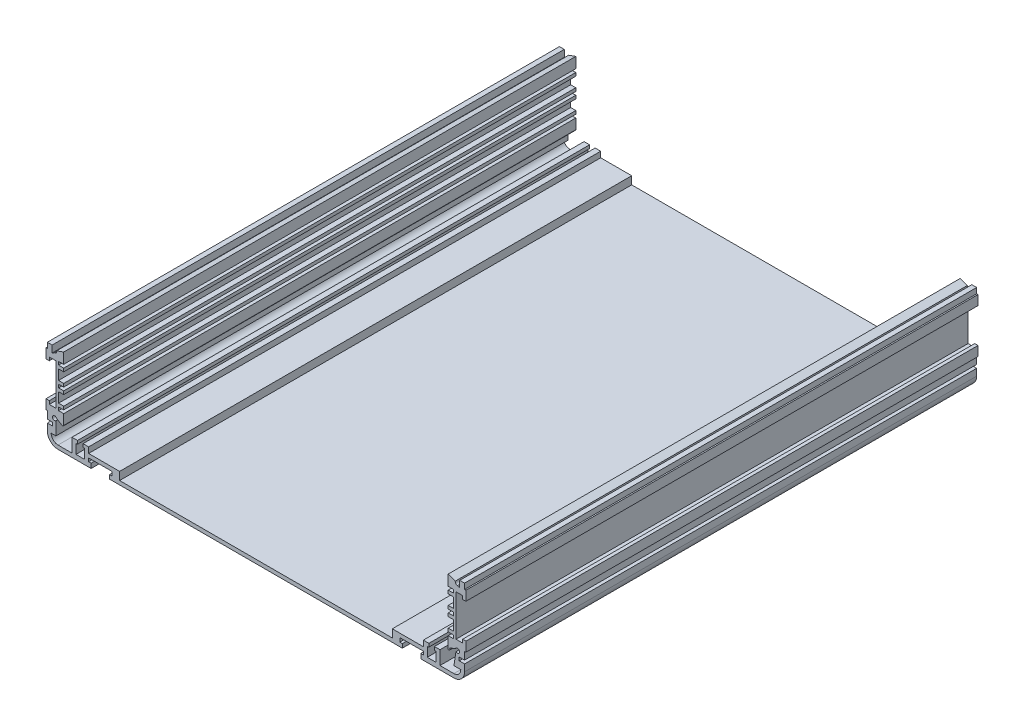
from build123d import *

# Parameters (mm, degrees)
MAINBODY_DEPTH = 304.8


with BuildPart() as part:
    # Sketch2 → MainBody (new body)
    with BuildSketch(Plane.XY):
        with BuildLine():
            Line((-87.11385, -52.07), (87.11385, -52.07))
            Line((87.11385, -52.07), (87.11385, -49.7078))
            Line((87.11385, -49.7078), (85.61385, -49.7078))
            Line((85.61385, -49.7078), (85.61385, -47.3456))
            Line((85.61385, -47.3456), (99.61385, -47.3456))
            Line((99.61385, -47.3456), (99.61385, -49.3141))
            Line((99.61385, -49.3141), (98.11385, -49.3141))
            Line((98.11385, -49.3141), (98.11385, -52.07))
            Line((98.11385, -52.07), (117.82425, -52.07))
            ThreePointArc((117.82425, -52.07), (122.314378061, -50.210128061), (124.17425, -45.72))
            Line((124.17425, -45.72), (124.17425, -41.656))
            Line((124.17425, -41.656), (120.99925, -41.656))
            Line((120.99925, -41.656), (120.99925, -39.6875))
            Line((120.99925, -39.6875), (124.17425, -39.6875))
            Line((124.17425, -39.6875), (124.17425, -35.2171))
            Line((124.17425, -35.2171), (124.968, -35.2171))
            Line((124.968, -35.2171), (124.968, -29.5021))
            Line((124.968, -29.5021), (122.9995, -29.5021))
            Line((122.9995, -29.5021), (122.9995, -31.4706))
            Line((122.9995, -31.4706), (119.0625, -31.4706))
            Line((119.0625, -31.4706), (119.0625, -7.0104))
            Line((119.0625, -7.0104), (122.9995, -7.0104))
            Line((122.9995, -7.0104), (122.9995, -8.9789))
            Line((122.9995, -8.9789), (124.968, -8.9789))
            Line((124.968, -8.9789), (124.968, -3.2639))
            Line((124.968, -3.2639), (124.17425, -3.2639))
            Line((124.17425, -3.2639), (124.17425, 0))
            Line((124.17425, 0), (121.29481323, 0))
            Line((121.29481323, 0), (121.29481323, -4.109997352))
            Line((121.29481323, -4.109997352), (120.011918892, -3.327689915))
            ThreePointArc((120.011918892, -3.327689915), (118.907723578, -2.871189246), (118.671208827, -1.699992881))
            Line((118.671208827, -1.699992881), (114.427, -0.1905))
            Line((114.427, -0.1905), (114.427, -6.5405))
            Line((114.427, -6.5405), (117.475, -6.5405))
            Line((117.475, -6.5405), (117.475, -8.4709))
            Line((117.475, -8.4709), (114.427, -8.4709))
            Line((114.427, -8.4709), (114.427, -10.4013))
            Line((114.427, -10.4013), (117.475, -10.4013))
            Line((117.475, -10.4013), (117.475, -16.3449))
            Line((117.475, -16.3449), (114.427, -16.3449))
            Line((114.427, -16.3449), (114.427, -18.2753))
            Line((114.427, -18.2753), (117.475, -18.2753))
            Line((117.475, -18.2753), (117.475, -20.2057))
            Line((117.475, -20.2057), (114.427, -20.2057))
            Line((114.427, -20.2057), (114.427, -22.1361))
            Line((114.427, -22.1361), (117.475, -22.1361))
            Line((117.475, -22.1361), (117.475, -28.0797))
            Line((117.475, -28.0797), (114.427, -28.0797))
            Line((114.427, -28.0797), (114.427, -30.0101))
            Line((114.427, -30.0101), (117.475, -30.0101))
            Line((117.475, -30.0101), (117.475, -31.9405))
            Line((117.475, -31.9405), (114.427, -31.9405))
            Line((114.427, -31.9405), (114.427, -39.0525))
            ThreePointArc((114.427, -39.0525), (115.382882445, -38.837450889), (115.167833333, -37.881568444))
            Line((115.167833333, -37.881568444), (118.737456339, -36.45102397))
            ThreePointArc((118.737456339, -36.45102397), (121.131104208, -36.728765521), (119.049383871, -37.942491573))
            Line((119.049383871, -37.942491573), (117.82425, -45.72))
            Line((117.82425, -45.72), (121.915072727, -45.72))
            ThreePointArc((121.915072727, -45.72), (120.716898491, -48.612648491), (117.82425, -49.810822727))
            Line((117.82425, -49.810822727), (109.51985, -49.810822727))
            Line((109.51985, -49.810822727), (109.51985, -41.656))
            Line((109.51985, -41.656), (106.21785, -41.656))
            Line((106.21785, -41.656), (106.21785, -43.6118))
            Line((106.21785, -43.6118), (107.15765, -43.6118))
            Line((107.15765, -43.6118), (107.15765, -49.3141))
            Line((107.15765, -49.3141), (101.97605, -49.3141))
            Line((101.97605, -49.3141), (101.97605, -43.6118))
            Line((101.97605, -43.6118), (102.91585, -43.6118))
            Line((102.91585, -43.6118), (102.91585, -41.656))
            Line((102.91585, -41.656), (99.61385, -41.656))
            Line((99.61385, -41.656), (99.61385, -45.0596))
            Line((99.61385, -45.0596), (81.154405407, -45.0596))
            Line((81.154405407, -45.0596), (81.154405407, -49.784))
            Line((81.154405407, -49.784), (-81.154405407, -49.784))
            Line((-81.154405407, -49.784), (-81.154405407, -45.0596))
            Line((-81.154405407, -45.0596), (-99.61385, -45.0596))
            Line((-99.61385, -45.0596), (-99.61385, -41.656))
            Line((-99.61385, -41.656), (-102.91585, -41.656))
            Line((-102.91585, -41.656), (-102.91585, -43.6118))
            Line((-102.91585, -43.6118), (-101.97605, -43.6118))
            Line((-101.97605, -43.6118), (-101.97605, -49.3141))
            Line((-101.97605, -49.3141), (-107.15765, -49.3141))
            Line((-107.15765, -49.3141), (-107.15765, -43.6118))
            Line((-107.15765, -43.6118), (-106.21785, -43.6118))
            Line((-106.21785, -43.6118), (-106.21785, -41.656))
            Line((-106.21785, -41.656), (-109.51985, -41.656))
            Line((-109.51985, -41.656), (-109.51985, -49.810822727))
            Line((-109.51985, -49.810822727), (-117.82425, -49.810822727))
            ThreePointArc((-117.82425, -49.810822727), (-120.716898491, -48.612648491), (-121.915072727, -45.72))
            Line((-121.915072727, -45.72), (-119.049383871, -45.72))
            Line((-119.049383871, -45.72), (-119.049383871, -37.942491573))
            ThreePointArc((-119.049383871, -37.942491573), (-121.131104208, -36.728765521), (-118.737456339, -36.45102397))
            Line((-118.737456339, -36.45102397), (-115.390113559, -38.471235131))
            ThreePointArc((-115.390113559, -38.471235131), (-114.749851886, -38.480556372), (-114.427, -37.927574858))
            Line((-114.427, -37.927574858), (-114.427, -31.9405))
            Line((-114.427, -31.9405), (-117.475, -31.9405))
            Line((-117.475, -31.9405), (-117.475, -30.0101))
            Line((-117.475, -30.0101), (-114.427, -30.0101))
            Line((-114.427, -30.0101), (-114.427, -28.0797))
            Line((-114.427, -28.0797), (-117.475, -28.0797))
            Line((-117.475, -28.0797), (-117.475, -22.1361))
            Line((-117.475, -22.1361), (-114.427, -22.1361))
            Line((-114.427, -22.1361), (-114.427, -20.2057))
            Line((-114.427, -20.2057), (-117.475, -20.2057))
            Line((-117.475, -20.2057), (-117.475, -18.2753))
            Line((-117.475, -18.2753), (-114.427, -18.2753))
            Line((-114.427, -18.2753), (-114.427, -16.3449))
            Line((-114.427, -16.3449), (-117.475, -16.3449))
            Line((-117.475, -16.3449), (-117.475, -10.4013))
            Line((-117.475, -10.4013), (-114.427, -10.4013))
            Line((-114.427, -10.4013), (-114.427, -8.4709))
            Line((-114.427, -8.4709), (-117.475, -8.4709))
            Line((-117.475, -8.4709), (-117.475, -6.5405))
            Line((-117.475, -6.5405), (-114.427, -6.5405))
            Line((-114.427, -6.5405), (-114.427, -0.1905))
            Line((-114.427, -0.1905), (-118.671208827, -1.699992881))
            ThreePointArc((-118.671208827, -1.699992881), (-118.907723578, -2.871189246), (-120.011918892, -3.327689915))
            Line((-120.011918892, -3.327689915), (-121.29481323, -4.109997352))
            Line((-121.29481323, -4.109997352), (-121.29481323, 0))
            Line((-121.29481323, 0), (-124.17425, 0))
            Line((-124.17425, 0), (-124.17425, -3.2639))
            Line((-124.17425, -3.2639), (-124.968, -3.2639))
            Line((-124.968, -3.2639), (-124.968, -8.9789))
            Line((-124.968, -8.9789), (-122.9995, -8.9789))
            Line((-122.9995, -8.9789), (-122.9995, -7.0104))
            Line((-122.9995, -7.0104), (-119.0625, -7.0104))
            Line((-119.0625, -7.0104), (-119.0625, -31.4706))
            Line((-119.0625, -31.4706), (-122.9995, -31.4706))
            Line((-122.9995, -31.4706), (-122.9995, -29.5021))
            Line((-122.9995, -29.5021), (-124.968, -29.5021))
            Line((-124.968, -29.5021), (-124.968, -35.2171))
            Line((-124.968, -35.2171), (-124.17425, -35.2171))
            Line((-124.17425, -35.2171), (-124.17425, -39.6875))
            Line((-124.17425, -39.6875), (-120.99925, -39.6875))
            Line((-120.99925, -39.6875), (-120.99925, -41.656))
            Line((-120.99925, -41.656), (-124.17425, -41.656))
            Line((-124.17425, -41.656), (-124.17425, -45.72))
            ThreePointArc((-124.17425, -45.72), (-122.314378061, -50.210128061), (-117.82425, -52.07))
            Line((-117.82425, -52.07), (-98.11385, -52.07))
            Line((-98.11385, -52.07), (-98.11385, -49.3141))
            Line((-98.11385, -49.3141), (-99.61385, -49.3141))
            Line((-99.61385, -49.3141), (-99.61385, -47.3456))
            Line((-99.61385, -47.3456), (-85.61385, -47.3456))
            Line((-85.61385, -47.3456), (-85.61385, -49.7078))
            Line((-85.61385, -49.7078), (-87.11385, -49.7078))
            Line((-87.11385, -49.7078), (-87.11385, -52.07))
        make_face()
    extrude(amount=MAINBODY_DEPTH)


solid = part.part
